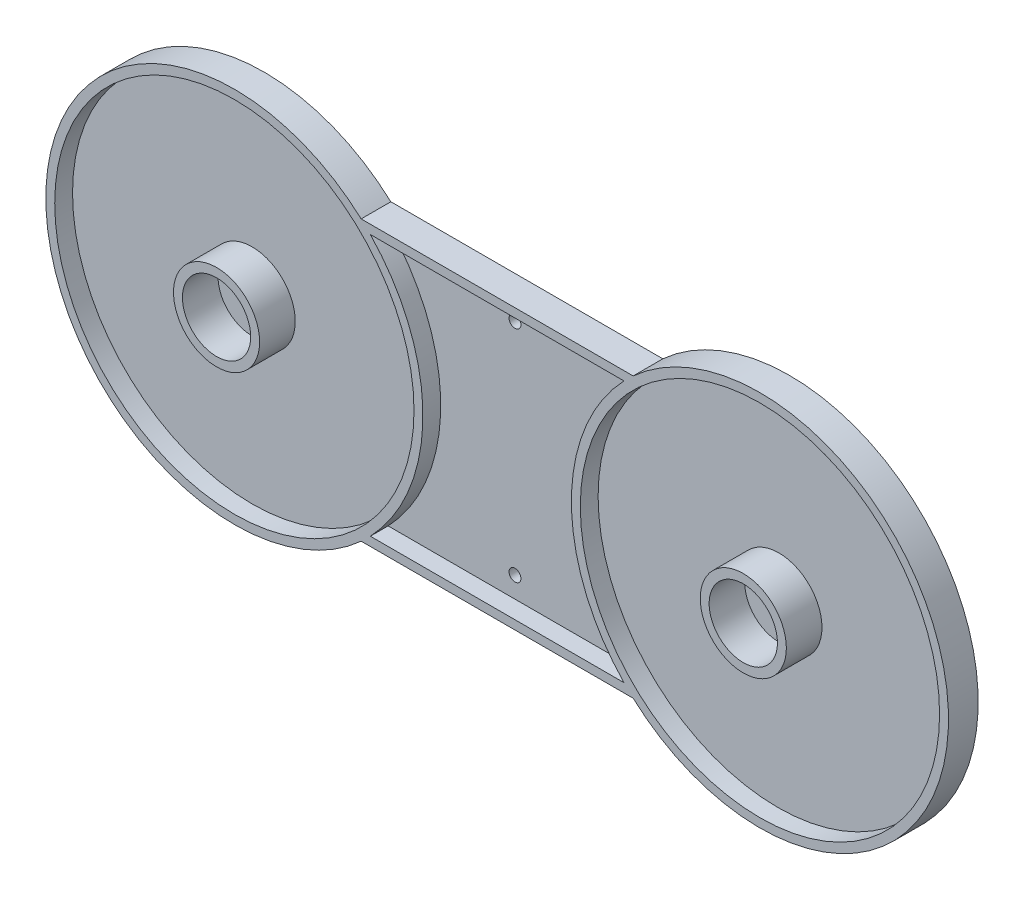
from build123d import *

# Parameters (mm, degrees)
BOSS_EXTRUDE1_DEPTH     = 2
SKETCH5_R               = 30.25
BOSS_EXTRUDE2_DEPTH     = 3
SKETCH6_R               = 7.25
SKETCH6_R_2             = 5.75
BOSS_EXTRUDE3_DEPTH     = 6
SKETCH7_R               = 1
CUT_EXTRUDE1_DEPTH      = 10
CUT_EXTRUDE1_DEPTH_BACK = 3


with BuildPart() as part:
    # Sketch3 → Boss-Extrude1 (new body)
    with BuildSketch(Plane.XY):
        with BuildLine():
            Line((22.900234193, 23.5), (-22.900234193, 23.5))
            ThreePointArc((-22.900234193, 23.5), (-76, 0), (-22.900234193, -23.5))
            Line((-22.900234193, -23.5), (22.900234193, -23.5))
            ThreePointArc((22.900234193, -23.5), (76, 0), (22.900234193, 23.5))
        make_face()
    extrude(amount=BOSS_EXTRUDE1_DEPTH)

    # Sketch5 → Boss-Extrude2 (add)
    with BuildSketch(Plane.XY.offset(2)):
        with BuildLine():
            Line((22.900234193, 23.5), (-22.900234193, 23.5))
            ThreePointArc((-22.900234193, 23.5), (-76, 0), (-22.900234193, -23.5))
            Line((-22.900234193, -23.5), (22.900234193, -23.5))
            ThreePointArc((22.900234193, -23.5), (76, 0), (22.900234193, 23.5))
        make_face()
        with Locations((-44.25, 0)):
            Circle(SKETCH5_R, mode=Mode.SUBTRACT)
        with Locations((44.25, 0)):
            Circle(SKETCH5_R, mode=Mode.SUBTRACT)
        with BuildLine():
            Line((-21.357588594, 22), (21.357588594, 22))
            ThreePointArc((21.357588594, 22), (12.5, 0), (21.357588594, -22))
            Line((21.357588594, -22), (-21.357588594, -22))
            ThreePointArc((-21.357588594, -22), (-12.5, 0), (-21.357588594, 22))
        make_face(mode=Mode.SUBTRACT)
    extrude(amount=BOSS_EXTRUDE2_DEPTH)

    # Sketch6 → Boss-Extrude3 (add)
    with BuildSketch(Plane.XY.offset(2)):
        with Locations((-44.25, 0)):
            Circle(SKETCH6_R)
        with Locations((-44.25, 0)):
            Circle(SKETCH6_R_2, mode=Mode.SUBTRACT)
        with Locations((44.447055655, -0.28653356)):
            Circle(SKETCH6_R)
        with Locations((44.447055655, -0.28653356)):
            Circle(SKETCH6_R_2, mode=Mode.SUBTRACT)
    extrude(amount=BOSS_EXTRUDE3_DEPTH)

    # Sketch7 → Cut-Extrude1 (cut, two sides)
    with BuildSketch(Plane.XY.offset(2)) as cut_extrude1_sk:
        with Locations((0, 18.5)):
            Circle(SKETCH7_R)
        with Locations((0, -18.5)):
            Circle(SKETCH7_R)
    extrude(amount=CUT_EXTRUDE1_DEPTH, mode=Mode.SUBTRACT)
    extrude(cut_extrude1_sk.sketch, amount=-CUT_EXTRUDE1_DEPTH_BACK, mode=Mode.SUBTRACT)


solid = part.part
